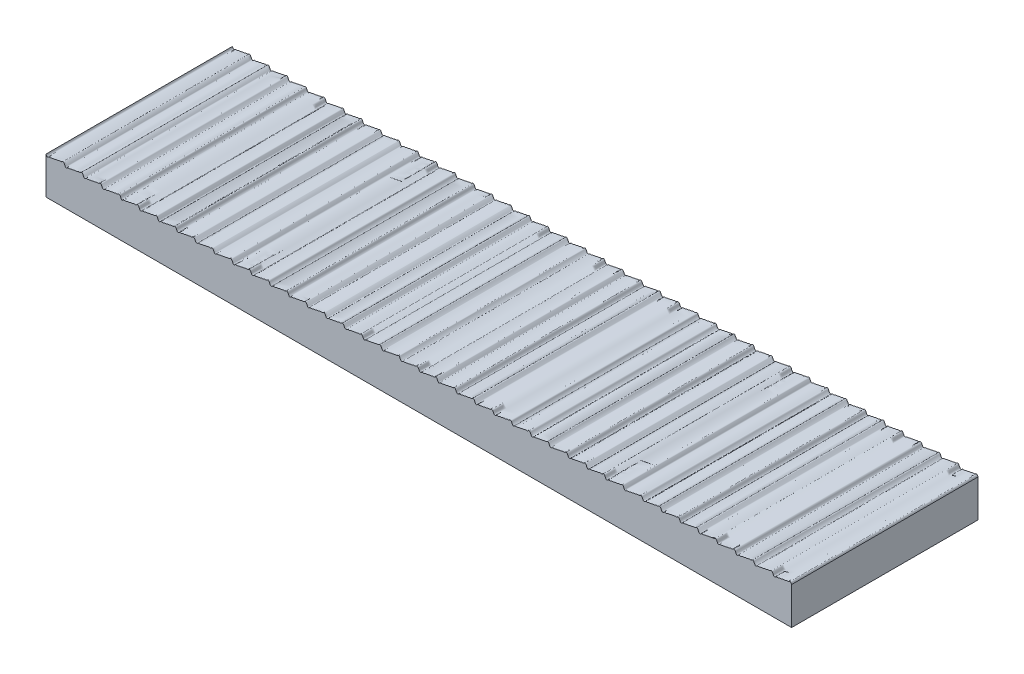
from build123d import *

# Parameters (mm, degrees)
AUFSATZ_LINEAR_AUSTRAGEN1_DEPTH = 50


with BuildPart() as part:
    # Skizze1 → Aufsatz-Linear austragen1 (new body)
    with BuildSketch(Plane.XY):
        with BuildLine():
            Line((0, 10), (0, 0))
            Line((0, 0), (200, 0))
            Line((200, 0), (200, 10))
            add(Edge.make_bspline(
                [(0, 10), (0.03137998, 9.937716), (0.094135611, 9.813155221), (0.236418355, 9.466195765), (0.604861974, 9.481054305), (0.873076513, 9.855216622), (1.294463976, 9.633381523), (1.623619706, 9.874234709), (1.995854247, 9.928287415), (2.385034214, 9.893234864), (2.712666782, 10.149058888), (3.116547038, 10.032493354), (3.451609554, 10.219154569), (3.806102109, 10.324222432), (4.187909618, 10.168439968), (4.464272127, 10.605205212), (4.840624593, 10.422836369), (4.95111014, 10.030104905), (5.116624305, 9.809589211), (5.289672506, 9.428206713), (5.623081072, 9.542716449), (5.809710554, 9.74991318), (6.082264674, 9.75112222), (6.372970751, 9.689977829), (6.659705391, 9.88294518), (7.000723868, 9.925127443), (7.390501799, 9.897672512), (7.711258183, 10.142149481), (8.088688725, 10.046377857), (8.407813535, 10.177763215), (8.704996424, 10.323510802), (9.057736245, 10.211375917), (9.298242273, 10.33843061), (9.622231708, 10.636371326), (9.947175599, 10.176268941), (10.004284425, 9.934756998), (10.369143735, 9.260427038), (10.790657676, 9.8096479), (11.158759527, 9.69930614), (11.564869193, 9.765611596), (11.88254191, 9.978833728), (12.303773958, 9.843237839), (12.625817255, 10.12299516), (13.023820491, 10.057968931), (13.359889757, 10.140825032), (13.643085668, 10.300715984), (13.946561396, 10.26399436), (14.194149845, 10.229569508), (14.441077276, 10.551870976), (14.80045316, 10.485215278), (14.980688128, 10.051931422), (15.109178204, 9.677718547), (15.517147753, 9.315772134), (15.871455194, 9.926344112), (16.29370232, 9.601986186), (16.64778739, 9.902061974), (17.006181745, 9.917894677), (17.406779296, 9.894494374), (17.722739904, 10.176539077), (18.156327379, 9.984449215), (18.47804792, 10.340314362), (18.983159393, 10.165597085), (19.302932525, 10.403983404), (19.759630634, 10.609339978), (19.933812297, 10.05761246), (20.077324513, 9.911778989), (20.228646386, 9.463546291), (20.615748335, 9.48816058), (20.873434911, 9.865042691), (21.316588043, 9.624322928), (21.639899597, 9.896189717), (22.021691661, 9.914771307), (22.398121646, 9.90977944), (22.723298034, 10.139432941), (23.109927541, 10.047908879), (23.431981851, 10.18722721), (23.779755133, 10.355849661), (24.160681136, 10.127561461), (24.478304241, 10.657461391), (24.905176271, 10.322989031), (25.009516317, 9.961580324), (25.222934589, 9.460508174), (25.605339343, 9.493882442), (25.83953464, 9.787113889), (26.1068472, 9.724569586), (26.394017494, 9.704630064), (26.679032895, 9.89399692), (27.023670711, 9.916563306), (27.407563671, 9.910681483), (27.731451743, 10.141897284), (28.09269152, 10.048990407), (28.410427087, 10.173757133), (28.679214276, 10.324671359), (29.048249796, 10.202177351), (29.293907866, 10.354095634), (29.665431556, 10.644322642), (29.96011601, 10.115229189), (30.032608345, 9.880090803), (30.389667082, 9.281744517), (30.759056304, 9.759584729), (31.073961204, 9.750270875), (31.421489964, 9.688772933), (31.695863332, 9.917235878), (32.052935466, 9.901744936), (32.410285387, 9.923321485), (32.753464532, 10.146504421), (33.131151365, 10.040279997), (33.45131742, 10.20674107), (33.736831605, 10.321366848), (34.089041619, 10.190316331), (34.318638703, 10.415417691), (34.720620427, 10.619901455), (34.958804891, 10.059699477), (35.070205695, 9.857033896), (35.322579864, 9.387412336), (35.677484278, 9.6042722), (35.876090355, 9.789251862), (36.225576977, 9.70209106), (36.505049539, 9.752147585), (36.81059294, 9.955469552), (37.166969188, 9.862676283), (37.508974603, 10.013411953), (37.867146126, 10.125738032), (38.24096266, 10.055845657), (38.536762755, 10.272351421), (38.842464696, 10.295283043), (39.153546143, 10.190491632), (39.392322826, 10.52580825), (39.774157311, 10.521675402), (39.983426121, 10.046504141), (40.080806499, 9.730507785), (40.473338432, 9.327766989), (40.800772962, 9.825119615), (41.141980683, 9.695575093), (41.507493645, 9.742786753), (41.804073573, 9.956496776), (42.183400464, 9.865926592), (42.521900352, 10.014801194), (42.867536629, 10.135262219), (43.280272915, 10.032365615), (43.586188794, 10.374799375), (44.058494899, 10.151653801), (44.324303227, 10.412197687), (44.69957089, 10.597226562), (44.901236304, 10.158718091), (45.043138506, 9.993677695), (45.178596033, 9.470249065), (45.638334577, 9.482946018), (45.946812689, 9.891218114), (46.436123761, 9.605176465), (46.755651235, 9.999127097), (47.170510663, 9.838957683), (47.515572399, 10.028504846), (47.864973821, 10.117756806), (48.262365294, 10.056504169), (48.554855754, 10.308943719), (48.953726277, 10.257719483), (49.238772405, 10.243147138), (49.5571684, 10.642918708), (49.863918578, 10.29975905), (50.016292078, 10.028037897), (50.159919621, 9.52346907), (50.582778757, 9.430984422), (50.8790325, 9.873889226), (51.29110505, 9.621141075), (51.620155209, 9.878929077), (51.989265622, 9.925242495), (52.381922777, 9.893350413), (52.708270347, 10.147301851), (53.122393692, 10.035053315), (53.449872352, 10.217500025), (53.831442124, 10.33417921), (54.188678531, 10.150352713), (54.515429267, 10.666710684), (54.901359477, 10.297305764), (55.013398913, 9.977758543), (55.204284841, 9.484984503), (55.579029785, 9.469956281), (55.820453803, 9.776467128), (56.075796547, 9.732830762), (56.372633917, 9.699462651), (56.654281336, 9.87522858), (56.996869404, 9.929567656), (57.383413198, 9.893417142), (57.706825398, 10.137956251), (58.063964646, 10.053961445), (58.387584355, 10.155191866), (58.650815428, 10.322304625), (59.019446828, 10.213277449), (59.272614598, 10.321024935), (59.646212583, 10.657767525), (59.969939637, 10.125103815), (60.02898502, 9.850872726), (60.418508289, 9.27626371), (60.780370087, 9.795234702), (61.088908655, 9.7247842), (61.419455753, 9.707306125), (61.68451587, 9.89760858), (62.030881744, 9.916137022), (62.387513027, 9.9037253), (62.72950613, 10.146358551), (63.103138455, 10.042072152), (63.430754717, 10.189325471), (63.707558341, 10.321760192), (64.064642114, 10.200587695), (64.295561638, 10.374370381), (64.696777252, 10.645079532), (64.948793768, 10.084597958), (65.064342191, 9.884376363), (65.291478982, 9.411289081), (65.652512182, 9.5624901), (65.854003563, 9.79419758), (66.198515673, 9.705599655), (66.485836691, 9.739793862), (66.786271939, 9.94861316), (67.142450332, 9.870918081), (67.487157739, 9.99117377), (67.842068878, 10.135289398), (68.214831807, 10.046883665), (68.516506219, 10.25958342), (68.810317636, 10.300917426), (69.132299072, 10.19147169), (69.364169859, 10.484813412), (69.753831604, 10.562854342), (69.976568145, 10.051844109), (70.070566858, 9.776853952), (70.442998838, 9.31540047), (70.782600391, 9.801714197), (71.112598962, 9.716304995), (71.488927846, 9.721650394), (71.78021892, 9.954968925), (72.158557759, 9.870330787), (72.501333526, 9.995175377), (72.841827196, 10.144114998), (73.258221726, 10.022341585), (73.564347016, 10.362830054), (74.030225672, 10.171097666), (74.308082654, 10.371924837), (74.671971024, 10.616644273), (74.904178348, 10.168018138), (75.037516974, 9.995846957), (75.192535741, 9.443206262), (75.651309824, 9.510728263), (75.955642265, 9.871384805), (76.420869898, 9.611723191), (76.734994389, 9.984364528), (77.144978296, 9.851000765), (77.496112912, 10.006071637), (77.840848869, 10.126976439), (78.239361983, 10.048156424), (78.53751289, 10.295145835), (78.923852896, 10.273580104), (79.224937734, 10.221412952), (79.535642387, 10.643487656), (79.878634677, 10.308256216), (80.011496173, 9.99966952), (80.181953902, 9.485835994), (80.593762969, 9.469028997), (80.854672643, 9.811399935), (81.164611487, 9.703554052), (81.479039458, 9.732403787), (81.77085282, 9.950671738), (82.148924421, 9.866083113), (82.507048594, 10.004326169), (82.844628455, 10.126602183), (83.223686341, 10.057215466), (83.504143218, 10.252463004), (83.845517693, 10.314506157), (84.18596099, 10.156197925), (84.508513181, 10.67209855), (84.888088562, 10.312452221), (85.018083399, 9.963637928), (85.193120949, 9.514932411), (85.556335544, 9.447215202), (85.804396283, 9.768188277), (86.050340027, 9.737142457), (86.353944635, 9.699092013), (86.636514457, 9.856050561), (86.971728286, 9.94380453), (87.369985961, 9.87497989), (87.692052009, 10.155035566), (88.11274531, 10.023430904), (88.432207692, 10.228666215), (88.836900409, 10.306288663), (89.205637795, 10.18333582), (89.623418927, 10.739241962), (89.996191575, 10.07391798), (90.048742659, 9.829809084), (90.373647542, 9.365109098), (90.699416099, 9.657179062), (90.938813677, 9.789987277), (91.291793479, 9.676538562), (91.589511276, 9.819916826), (91.908094407, 9.954283293), (92.285812517, 9.857224057), (92.607000351, 10.10065488), (92.996180193, 10.076079321), (93.338519698, 10.115304391), (93.625320555, 10.310030591), (93.9175388, 10.249121334), (94.190676919, 10.249590795), (94.378072328, 10.459069525), (94.711042293, 10.569602917), (94.882472167, 10.19219863), (95.048239167, 9.970602314), (95.156899464, 9.5834941), (95.531674404, 9.391420524), (95.809945735, 9.831057299), (96.191792527, 9.676655503), (96.547907697, 9.779765491), (96.882714479, 9.967802169), (97.286202772, 9.850832636), (97.614994497, 10.10610998), (98.001803504, 10.072462177), (98.377879795, 10.124353544), (98.701678199, 10.368529251), (99.136233055, 10.140767839), (99.385333937, 10.528837005), (99.78653764, 10.522024747), (99.915746819, 10.083309522), (100.084253168, 9.916690503), (100.213462347, 9.477975278), (100.61466605, 9.47116302), (100.863766933, 9.859232186), (101.298321788, 9.631470774), (101.622120193, 9.875646481), (101.998196484, 9.927537848), (102.38500549, 9.893890045), (102.713797216, 10.149167389), (103.117285508, 10.032197856), (103.45209229, 10.220234534), (103.808207461, 10.323344522), (104.190054253, 10.168942726), (104.468325583, 10.608579501), (104.843100523, 10.416505925), (104.951760821, 10.029397711), (105.117527821, 9.807801395), (105.288957695, 9.430397108), (105.621927659, 9.5409305), (105.809323068, 9.75040923), (106.082461188, 9.750878691), (106.374679432, 9.689969434), (106.661480289, 9.884695634), (107.003819794, 9.923920704), (107.392999636, 9.899345145), (107.71418747, 10.142775968), (108.091905581, 10.045716732), (108.410488711, 10.180083199), (108.708206508, 10.323461463), (109.061186311, 10.210012748), (109.300583889, 10.342820963), (109.626352445, 10.634890927), (109.951257329, 10.170190941), (110.003808412, 9.926082045), (110.37658106, 9.260758063), (110.794362192, 9.816664205), (111.163099579, 9.693711362), (111.567792296, 9.77133381), (111.887254678, 9.976569121), (112.307947978, 9.844964459), (112.630014027, 10.125020135), (113.028271701, 10.056195495), (113.363485531, 10.143949464), (113.646055352, 10.300908012), (113.94965996, 10.262857568), (114.195603704, 10.231811748), (114.443664444, 10.552784823), (114.806879038, 10.485067614), (114.981916589, 10.036362098), (115.111911426, 9.687547804), (115.491486806, 9.327901475), (115.814038997, 9.8438021), (116.154482294, 9.685493868), (116.49585677, 9.747537021), (116.776313646, 9.942784559), (117.155371532, 9.873397842), (117.492951393, 9.995673856), (117.851075566, 10.133916912), (118.229147167, 10.049328287), (118.520960529, 10.267596238), (118.8353885, 10.296445973), (119.145327345, 10.18860009), (119.406237018, 10.530971028), (119.818046085, 10.514164031), (119.988503814, 10.000330505), (120.12136531, 9.691743809), (120.4643576, 9.356512369), (120.775062253, 9.778587073), (121.076147091, 9.726419921), (121.462487098, 9.70485419), (121.760638005, 9.951843601), (122.159151119, 9.873023586), (122.503887075, 9.993928388), (122.855021692, 10.14899926), (123.265005599, 10.015635497), (123.579130089, 10.388276834), (124.044357722, 10.12861522), (124.348690164, 10.489271762), (124.807464246, 10.556793763), (124.962483014, 10.004153068), (125.09582164, 9.831981887), (125.328028963, 9.383355752), (125.691917333, 9.628075188), (125.969774315, 9.828902359), (126.435652971, 9.637169971), (126.741778262, 9.97765844), (127.158172791, 9.855885027), (127.498666461, 10.004824648), (127.841442229, 10.129669238), (128.219781068, 10.0450311), (128.511072142, 10.278349631), (128.887401025, 10.28369503), (129.217399597, 10.198285828), (129.557001149, 10.684599555), (129.92943313, 10.223146073), (130.023431843, 9.948155916), (130.246168383, 9.437145683), (130.635830128, 9.515186613), (130.867700916, 9.808528335), (131.189682352, 9.699082599), (131.483493768, 9.740416605), (131.78516818, 9.95311636), (132.15793111, 9.864710627), (132.512842248, 10.008826256), (132.857549655, 10.129081944), (133.213728048, 10.051386865), (133.514163296, 10.260206163), (133.801484314, 10.29440037), (134.145996424, 10.205802445), (134.347487806, 10.437509925), (134.708521005, 10.588710944), (134.935657797, 10.115623662), (135.05120622, 9.915402067), (135.303222735, 9.354920493), (135.704438349, 9.625629644), (135.935357874, 9.79941233), (136.292441647, 9.678239833), (136.569245271, 9.810674554), (136.896861532, 9.957927873), (137.270493857, 9.853641474), (137.61248696, 10.096274725), (137.969118243, 10.083863003), (138.315484117, 10.102391445), (138.580544235, 10.2926939), (138.911091333, 10.275215825), (139.219629901, 10.204765323), (139.581491699, 10.723736315), (139.971014968, 10.149127299), (140.030060351, 9.87489621), (140.353787404, 9.3422325), (140.727385389, 9.67897509), (140.98055316, 9.786722576), (141.349184559, 9.6776954), (141.612415632, 9.844808159), (141.936035341, 9.94603858), (142.29317459, 9.862043774), (142.61658679, 10.106582883), (143.003130584, 10.070432369), (143.345718651, 10.124771445), (143.62736607, 10.300537374), (143.92420344, 10.267169263), (144.179546185, 10.223532897), (144.420970203, 10.530043744), (144.795715146, 10.515015522), (144.986601074, 10.022241482), (145.098640511, 9.702694261), (145.48457072, 9.333289341), (145.811321457, 9.849647312), (146.168557864, 9.665820815), (146.550127636, 9.7825), (146.877606295, 9.96494671), (147.29172964, 9.852698174), (147.61807721, 10.106649612), (148.010734365, 10.07475753), (148.379844778, 10.121070948), (148.708894937, 10.37885895), (149.120967488, 10.126110799), (149.417221231, 10.569015603), (149.840080367, 10.476530955), (149.98370791, 9.971962128), (150.13608141, 9.700240975), (150.442831588, 9.357081317), (150.761227582, 9.756852887), (151.04627371, 9.742280542), (151.445144233, 9.691056307), (151.737634693, 9.943495856), (152.135026166, 9.882243219), (152.484427589, 9.971495179), (152.829489325, 10.161042342), (153.244348752, 10.000872928), (153.563876226, 10.39482356), (154.053187298, 10.108781911), (154.36166541, 10.517054007), (154.821403954, 10.52975096), (154.956861481, 10.00632233), (155.098763683, 9.841281934), (155.300429098, 9.402773463), (155.67569676, 9.587802338), (155.941505088, 9.848346224), (156.413811194, 9.62520065), (156.719727073, 9.96763441), (157.132463358, 9.864737807), (157.478099635, 9.985198831), (157.816599524, 10.134073433), (158.195926415, 10.043503249), (158.492506343, 10.257213272), (158.858019304, 10.304424932), (159.199227026, 10.17488041), (159.526661556, 10.672233036), (159.919193489, 10.26949224), (160.016573866, 9.953495884), (160.225842676, 9.478324623), (160.607677161, 9.474191775), (160.846453844, 9.809508393), (161.157535291, 9.704716982), (161.463237233, 9.727648604), (161.759037328, 9.944154368), (162.132853862, 9.874261993), (162.491025385, 9.986588072), (162.833030799, 10.137323742), (163.189407047, 10.044530473), (163.494950448, 10.24785244), (163.77442301, 10.297908965), (164.123909632, 10.210748163), (164.322515709, 10.395727825), (164.677420124, 10.612587689), (164.929794292, 10.142966129), (165.041195096, 9.940300548), (165.27937956, 9.38009857), (165.681361284, 9.584582334), (165.910958369, 9.809683694), (166.263168382, 9.678633177), (166.548682567, 9.793258955), (166.868848623, 9.959720028), (167.246535455, 9.853495604), (167.5897146, 10.07667854), (167.947064521, 10.098255089), (168.304136655, 10.082764147), (168.578510024, 10.311227093), (168.926038783, 10.24972915), (169.240943683, 10.240415296), (169.610332905, 10.718255508), (169.967391643, 10.119909222), (170.039883977, 9.884770836), (170.334568431, 9.355677383), (170.706092121, 9.645904391), (170.951750191, 9.797822674), (171.320785712, 9.675328666), (171.5895729, 9.826242892), (171.907308467, 9.951009618), (172.268548244, 9.858102741), (172.592436316, 10.089318542), (172.976329276, 10.083436719), (173.320967092, 10.106003105), (173.605982493, 10.295369961), (173.893152788, 10.275430439), (174.160465347, 10.212886136), (174.394660644, 10.506117583), (174.777065399, 10.539491851), (174.99048367, 10.038419701), (175.094823716, 9.677010994), (175.521695746, 9.342538634), (175.839318851, 9.872438564), (176.220244854, 9.644150364), (176.568018136, 9.812772815), (176.890072446, 9.952091146), (177.276701953, 9.860567084), (177.601878341, 10.090220585), (177.978308326, 10.085228718), (178.36010039, 10.103810308), (178.683411944, 10.375677097), (179.126565077, 10.134957334), (179.384251652, 10.511839445), (179.771353601, 10.536453734), (179.922675475, 10.088221036), (180.06618769, 9.942387565), (180.240369354, 9.390660047), (180.697067462, 9.596016621), (181.016840595, 9.83440294), (181.521952067, 9.659685663), (181.843672609, 10.01555081), (182.277260084, 9.823460948), (182.593220691, 10.105505651), (182.993818243, 10.082105348), (183.352212597, 10.097938051), (183.706297667, 10.398013839), (184.128544793, 10.073655913), (184.482852234, 10.684227891), (184.890821783, 10.322281478), (185.01931186, 9.948068603), (185.199546828, 9.514784747), (185.558922712, 9.448129049), (185.805850142, 9.770430517), (186.053438592, 9.736005665), (186.35691432, 9.699284041), (186.64011023, 9.859174993), (186.976179497, 9.942031094), (187.374182733, 9.877004865), (187.696226029, 10.156762186), (188.117458078, 10.021166297), (188.435130795, 10.234388429), (188.84124046, 10.300693885), (189.209342312, 10.190352125), (189.630856252, 10.739572987), (189.995715562, 10.065243027), (190.052824388, 9.823731085), (190.377768279, 9.363628699), (190.701757714, 9.661569415), (190.942263742, 9.788624108), (191.295003564, 9.676489223), (191.592186452, 9.82223681), (191.911311262, 9.953622168), (192.288741805, 9.857850544), (192.609498189, 10.102327513), (192.999276119, 10.074872582), (193.340294596, 10.117054845), (193.627029237, 10.310022196), (193.917735314, 10.248877805), (194.190289433, 10.250086845), (194.376918915, 10.457283576), (194.710327482, 10.571793312), (194.883375682, 10.190410814), (195.048889848, 9.96989512), (195.159375394, 9.577163656), (195.53572786, 9.394794813), (195.812090369, 9.831560057), (196.193897878, 9.675777593), (196.548390434, 9.780845456), (196.883452949, 9.967506671), (197.287333205, 9.850941137), (197.614965774, 10.106765161), (198.004145741, 10.07171261), (198.376380282, 10.125765316), (198.705536011, 10.366618502), (199.126923475, 10.144783403), (199.395138013, 10.51894572), (199.763581632, 10.53380426), (199.905864376, 10.186844804), (199.968620007, 10.062284025), (200, 10)],
                knots=[0.08208364, 0.08208364, 0.08208364, 0.08208364, 0.08208364, 0.083303964, 0.084524287, 0.085865235, 0.087206183, 0.088589562, 0.089972941, 0.09135632, 0.092739698, 0.0940995, 0.095459302, 0.096819103, 0.098178905, 0.099455347, 0.10073179, 0.102071564, 0.103411339, 0.104582955, 0.105754572, 0.106692774, 0.107630976, 0.108569178, 0.109507381, 0.110890378, 0.112273375, 0.113656372, 0.115039369, 0.116239119, 0.117438868, 0.118638618, 0.119838367, 0.120831692, 0.121825018, 0.123624986, 0.125424954, 0.127273389, 0.128654447, 0.130035505, 0.131416562, 0.13279762, 0.134181648, 0.135565676, 0.136949704, 0.138333732, 0.139262639, 0.140191547, 0.141120455, 0.142049363, 0.143754495, 0.145253923, 0.146753351, 0.148570992, 0.149950464, 0.151329937, 0.152709409, 0.154088881, 0.155472768, 0.156856654, 0.15824054, 0.159624426, 0.161416375, 0.163208323, 0.16447164, 0.165734956, 0.166893266, 0.168051575, 0.169453824, 0.170856072, 0.172238063, 0.173620053, 0.175002044, 0.176384035, 0.177681898, 0.178979761, 0.180277624, 0.181575487, 0.182943393, 0.184311298, 0.18602184, 0.187732382, 0.189439715, 0.190366416, 0.191293117, 0.192219818, 0.193146519, 0.194529814, 0.195913109, 0.197296404, 0.198679699, 0.199820726, 0.200961753, 0.20210278, 0.203243807, 0.204479204, 0.205714602, 0.207407502, 0.209100402, 0.210910501, 0.212046693, 0.213182884, 0.214319076, 0.215455268, 0.216836934, 0.2182186, 0.219600266, 0.220981932, 0.22208486, 0.223187788, 0.224290716, 0.225393644, 0.226849145, 0.228544731, 0.230240317, 0.23123466, 0.232229002, 0.233362574, 0.234496145, 0.235629717, 0.236763288, 0.238146192, 0.239529095, 0.240911998, 0.242294901, 0.243349227, 0.244403552, 0.245457878, 0.246512203, 0.247993036, 0.249678694, 0.251364352, 0.252684817, 0.254005283, 0.255270367, 0.256535451, 0.257800535, 0.25906562, 0.260447895, 0.26183017, 0.263212445, 0.26459472, 0.266102189, 0.267609658, 0.268651798, 0.269693937, 0.271090387, 0.272486836, 0.274159408, 0.275831981, 0.277215399, 0.278598818, 0.279982237, 0.281365655, 0.282691742, 0.284017828, 0.285343914, 0.28667, 0.287783313, 0.288896625, 0.290349326, 0.291802028, 0.293568002, 0.294854353, 0.296140704, 0.297522662, 0.298904619, 0.300286577, 0.301668534, 0.303047917, 0.304427299, 0.305806682, 0.307186064, 0.308480156, 0.309774247, 0.311383678, 0.31299311, 0.31473036, 0.315655265, 0.316580171, 0.317505076, 0.318429981, 0.319813194, 0.321196406, 0.322579619, 0.323962832, 0.325101117, 0.326239402, 0.327377687, 0.328515971, 0.329759938, 0.331003904, 0.332810145, 0.334616387, 0.336420765, 0.337500904, 0.338581043, 0.339661182, 0.340741321, 0.342121654, 0.343501987, 0.34488232, 0.346262653, 0.347364838, 0.348467023, 0.349569208, 0.350671394, 0.352154044, 0.353815168, 0.355476291, 0.356498251, 0.357520211, 0.358652689, 0.359785167, 0.360917645, 0.362050122, 0.363431721, 0.364813319, 0.366194918, 0.367576517, 0.368628558, 0.369680599, 0.37073264, 0.371784681, 0.373294784, 0.374960282, 0.37662578, 0.377962353, 0.379298925, 0.38056236, 0.381825795, 0.38308923, 0.384352665, 0.385735693, 0.387118722, 0.38850175, 0.389884778, 0.391387696, 0.392890613, 0.393945657, 0.395000701, 0.396524202, 0.398047704, 0.399588791, 0.401129878, 0.402513217, 0.403896557, 0.405279897, 0.406663236, 0.407989999, 0.409316762, 0.410643524, 0.411970287, 0.413081862, 0.414193438, 0.415774994, 0.41735655, 0.41916961, 0.420234175, 0.421298739, 0.422363303, 0.423427868, 0.424810971, 0.426194074, 0.427577178, 0.428960281, 0.430132078, 0.431303875, 0.432475673, 0.43364747, 0.435283862, 0.436788903, 0.438293944, 0.440034818, 0.440960232, 0.441885645, 0.442811059, 0.443736472, 0.445119829, 0.446503185, 0.447886541, 0.449269897, 0.450652937, 0.452035976, 0.453419016, 0.454802055, 0.456617664, 0.458432986, 0.460248308, 0.461241574, 0.46223484, 0.463434621, 0.464634402, 0.465834183, 0.467033965, 0.46841757, 0.469801175, 0.471184781, 0.472568386, 0.47351136, 0.474454335, 0.475397309, 0.476340284, 0.477502182, 0.478664081, 0.479996764, 0.481329447, 0.482615637, 0.483901827, 0.485261761, 0.486621694, 0.487981628, 0.489341561, 0.490724609, 0.492107657, 0.493490705, 0.494873753, 0.496232677, 0.497591601, 0.498795801, 0.5, 0.501204199, 0.502408399, 0.503767323, 0.505126247, 0.506509295, 0.507892343, 0.509275391, 0.510658439, 0.512018372, 0.513378306, 0.514738239, 0.516098173, 0.517384363, 0.518670553, 0.520003236, 0.521335919, 0.522497818, 0.523659716, 0.524602691, 0.525545665, 0.52648864, 0.527431614, 0.528815219, 0.530198825, 0.53158243, 0.532966035, 0.534165817, 0.535365598, 0.536565379, 0.53776516, 0.538758426, 0.539751692, 0.541567014, 0.543382336, 0.545197945, 0.546580984, 0.547964024, 0.549347063, 0.550730103, 0.552113459, 0.553496815, 0.554880171, 0.556263528, 0.557188941, 0.558114355, 0.559039768, 0.559965182, 0.561706056, 0.563211097, 0.564716138, 0.56635253, 0.567524327, 0.568696125, 0.569867922, 0.571039719, 0.572422822, 0.573805926, 0.575189029, 0.576572132, 0.577636697, 0.578701261, 0.579765825, 0.58083039, 0.58264345, 0.584225006, 0.585806562, 0.586918138, 0.588029713, 0.589356476, 0.590683238, 0.592010001, 0.593336764, 0.594720103, 0.596103443, 0.597486783, 0.598870122, 0.600411209, 0.601952296, 0.603475798, 0.604999299, 0.606054343, 0.607109387, 0.608612304, 0.610115222, 0.61149825, 0.612881278, 0.614264307, 0.615647335, 0.61691077, 0.618174205, 0.61943764, 0.620701075, 0.622037647, 0.62337422, 0.625039718, 0.626705216, 0.628215319, 0.62926736, 0.630319401, 0.631371442, 0.632423483, 0.633805082, 0.635186681, 0.636568279, 0.637949878, 0.639082355, 0.640214833, 0.641347311, 0.642479789, 0.643501749, 0.644523709, 0.646184832, 0.647845956, 0.649328606, 0.650430792, 0.651532977, 0.652635162, 0.653737347, 0.65511768, 0.656498013, 0.657878346, 0.659258679, 0.660338818, 0.661418957, 0.662499096, 0.663579235, 0.665383613, 0.667189855, 0.668996096, 0.670240062, 0.671484029, 0.672622313, 0.673760598, 0.674898883, 0.676037168, 0.677420381, 0.678803594, 0.680186806, 0.681570019, 0.682494924, 0.683419829, 0.684344735, 0.68526964, 0.68700689, 0.688616322, 0.690225753, 0.691519844, 0.692813936, 0.694193318, 0.695572701, 0.696952083, 0.698331466, 0.699713423, 0.701095381, 0.702477338, 0.703859296, 0.705145647, 0.706431998, 0.708197972, 0.709650674, 0.711103375, 0.712216687, 0.71333, 0.714656086, 0.715982172, 0.717308258, 0.718634345, 0.720017763, 0.721401182, 0.722784601, 0.724168019, 0.725840592, 0.727513164, 0.728909613, 0.730306063, 0.731348202, 0.732390342, 0.733897811, 0.73540528, 0.736787555, 0.73816983, 0.739552105, 0.74093438, 0.742199465, 0.743464549, 0.744729633, 0.745994717, 0.747315183, 0.748635648, 0.750321306, 0.752006964, 0.753487797, 0.754542122, 0.755596448, 0.756650773, 0.757705099, 0.759088002, 0.760470905, 0.761853808, 0.763236712, 0.764370283, 0.765503855, 0.766637426, 0.767770998, 0.76876534, 0.769759683, 0.771455269, 0.773150855, 0.774606356, 0.775709284, 0.776812212, 0.77791514, 0.779018068, 0.780399734, 0.7817814, 0.783163066, 0.784544732, 0.785680924, 0.786817116, 0.787953307, 0.789089499, 0.790899598, 0.792592498, 0.794285398, 0.795520796, 0.796756193, 0.79789722, 0.799038247, 0.800179274, 0.801320301, 0.802703596, 0.804086891, 0.805470186, 0.806853481, 0.807780182, 0.808706883, 0.809633584, 0.810560285, 0.812267618, 0.81397816, 0.815688702, 0.817056607, 0.818424513, 0.819722376, 0.821020239, 0.822318102, 0.823615965, 0.824997956, 0.826379947, 0.827761937, 0.829143928, 0.830546176, 0.831948425, 0.833106734, 0.834265044, 0.83552836, 0.836791677, 0.838583625, 0.840375574, 0.84175946, 0.843143346, 0.844527232, 0.845911119, 0.847290591, 0.848670063, 0.850049536, 0.851429008, 0.853246649, 0.854746077, 0.856245505, 0.857950637, 0.858879545, 0.859808453, 0.860737361, 0.861666268, 0.863050296, 0.864434324, 0.865818352, 0.86720238, 0.868583438, 0.869964495, 0.871345553, 0.872726611, 0.874575046, 0.876375014, 0.878174982, 0.879168308, 0.880161633, 0.881361382, 0.882561132, 0.883760881, 0.884960631, 0.886343628, 0.887726625, 0.889109622, 0.890492619, 0.891430822, 0.892369024, 0.893307226, 0.894245428, 0.895417045, 0.896588661, 0.897928436, 0.89926821, 0.900544653, 0.901821095, 0.903180897, 0.904540698, 0.9059005, 0.907260302, 0.90864368, 0.910027059, 0.911410438, 0.912793817, 0.914134765, 0.915475713, 0.916696036, 0.91791636, 0.91791636, 0.91791636, 0.91791636, 0.91791636], degree=4))
        make_face()
    extrude(amount=AUFSATZ_LINEAR_AUSTRAGEN1_DEPTH)


solid = part.part
